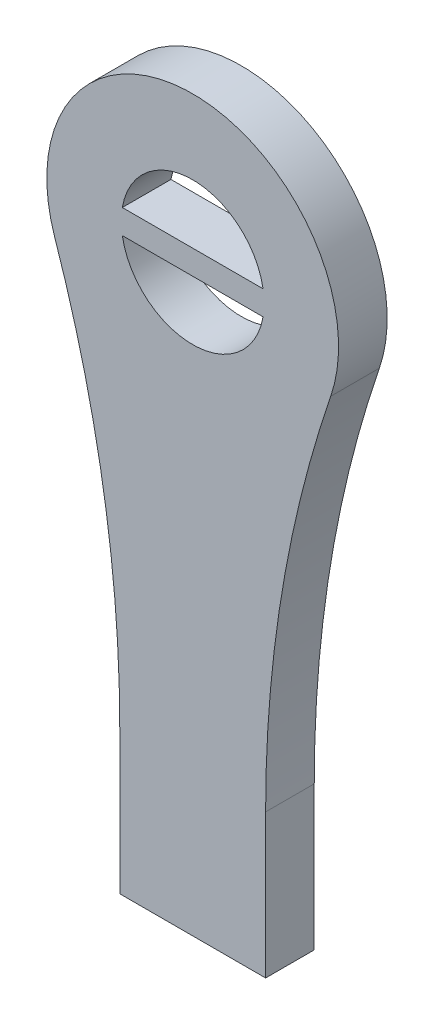
from build123d import *

# Parameters (mm, degrees)
BOSS_EXTRUDE1_DEPTH = 2


with BuildPart() as part:
    # Model → Boss-Extrude1 (new body)
    with BuildSketch(Plane.XY):
        with BuildLine():
            Line((58.08314132, -82), (58.08314132, -87.91685868))
            Line((58.08314132, -87.91685868), (52.08314132, -87.91685868))
            Line((52.08314132, -87.91685868), (52.08314132, -82))
            ThreePointArc((52.08314132, -82), (51.408953166, -73.816829116), (49.404569891, -65.854338107))
            ThreePointArc((49.404569891, -65.854338107), (55.08314132, -57.91685868), (60.761712749, -65.854338107))
            ThreePointArc((60.761712749, -65.854338107), (58.757329474, -73.816829116), (58.08314132, -82))
        make_face()
        with BuildLine():
            Line((52.188507276, -64.41685868), (57.977775364, -64.41685868))
            ThreePointArc((57.977775364, -64.41685868), (55.08314132, -66.85435868), (52.188507276, -64.41685868))
        make_face(mode=Mode.SUBTRACT)
        with BuildLine():
            Line((57.977775364, -63.41685868), (52.188507276, -63.41685868))
            ThreePointArc((52.188507276, -63.41685868), (55.08314132, -60.97935868), (57.977775364, -63.41685868))
        make_face(mode=Mode.SUBTRACT)
    extrude(amount=BOSS_EXTRUDE1_DEPTH)


solid = part.part
